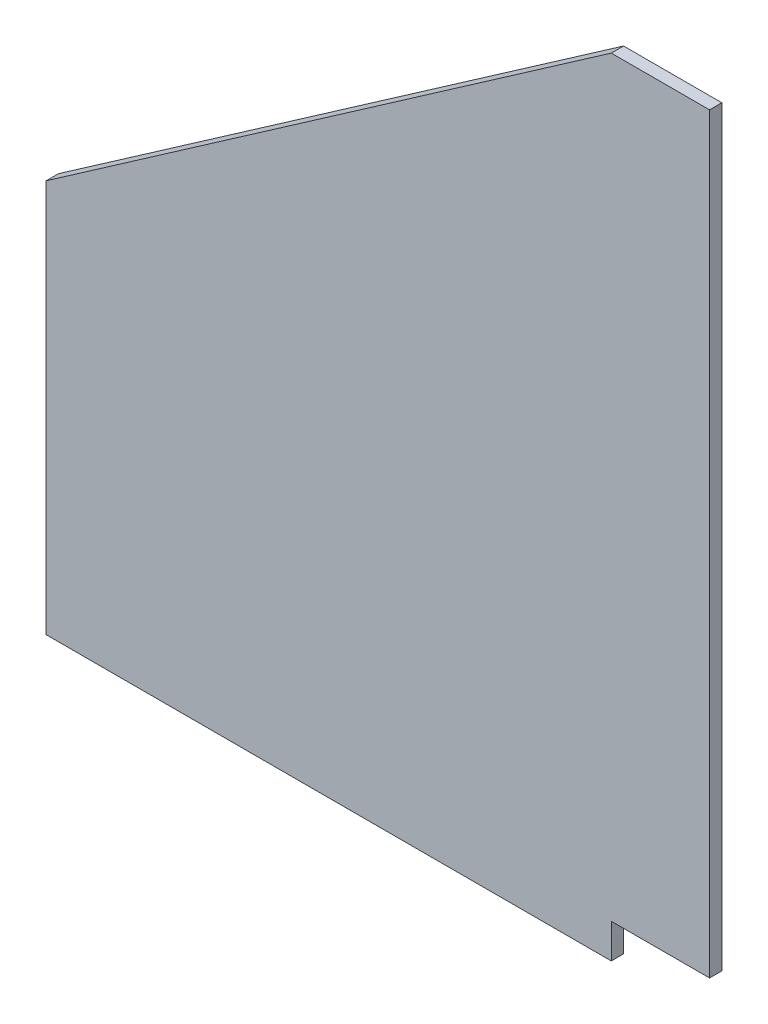
from build123d import *

# Parameters (mm, degrees)
BOSS_EXTRUDE1_DEPTH = 3.175


with BuildPart() as part:
    # Sketch1 → Boss-Extrude1 (new body)
    with BuildSketch(Plane.XY):
        Polygon((0, 0), (0, 194.31), (-25.4, 194.31), (-171.45, 92.71), (-171.45, -8.89), (-25.4, -8.89), (-25.4, 0), align=None)
    extrude(amount=BOSS_EXTRUDE1_DEPTH)


solid = part.part
